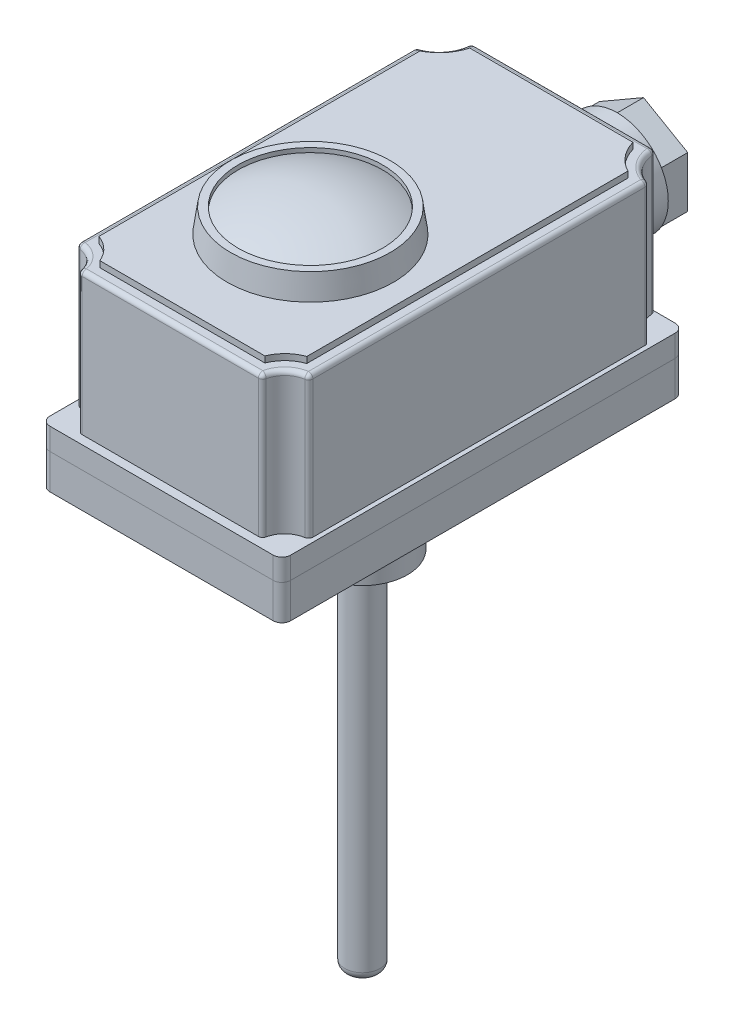
from build123d import *

# Parameters (mm, degrees)
SKICA1_W                 = 55
SKICA1_H                 = 91.8
P_IDAT_VYSUNUT_M1_DEPTH  = 8
SKICA2_W                 = 55
SKICA2_H                 = 91.8
P_IDAT_VYSUNUT_M2_DEPTH  = 5
P_IDAT_VYSUNUT_M3_DEPTH  = 32.3
P_IDAT_VYSUNUT_M4_DEPTH  = 1.4
ZAOBLIT1_R               = 1
ZAOBLIT1_2_R             = 2
ZAOBLIT2_R               = 2
SKICA5_R                 = 11.65
P_IDAT_VYSUNUT_M5_DEPTH  = 12.3
P_IDAT_VYSUNUT_M6_DEPTH  = 6
ODEBRAT_START            = 1
SKICA6_3_R               = 7.75
ODEBRAT_VYSUNUT_M1_DEPTH = 5
SKICA9_R                 = 19
P_IDAT_VYSUNUT_M8_DEPTH  = 5.5
P_IDAT_VYSUNUT_M8_TAPER  = 8
SKICA10_R                = 16.5
ODEBRAT_VYSUNUT_M2_DEPTH = 1
KOPULE1_FACE_RADIUS      = 16.5
KOPULE1_HEIGHT           = 4
SKICA11_R                = 16.5
SKICA11_R_2              = 13.25
P_IDAT_VYSUNUT_M9_DEPTH  = 10
P_IDAT_VYSUNUT_M10_DEPTH = 11
SKICA13_R                = 10.25
P_IDAT_VYSUNUT_M11_DEPTH = 10.5
SKICA14_R                = 4
P_IDAT_VYSUNUT_M12_DEPTH = 83
ZAOBLIT3_R               = 2


with BuildPart() as part:
    # Skica1 → P_idat vysunut_m1 (new body)
    with BuildSketch(Plane(origin=(0, 0, 0), x_dir=(1, 0, 0), z_dir=(0, 1, 0))):
        Rectangle(SKICA1_W, SKICA1_H)
    extrude(amount=P_IDAT_VYSUNUT_M1_DEPTH)

    # Zaoblit2
    zaoblit2_edges = [part.edges().sort_by_distance(p)[0] for p in [
        (27.5, 4, 45.9),
        (-27.5, 4, 45.9),
        (-27.5, 4, -45.9),
        (27.5, 4, -45.9),
    ]]
    fillet(zaoblit2_edges, radius=ZAOBLIT2_R)

    # Skica11 → P_idat vysunut_m9 (add)
    with BuildSketch(Plane.XZ):
        with Locations(Location((0, 0, 0), (0, 0, 270))):  # turned: the seam where the file's is
            Circle(SKICA11_R)
        with Locations(Location((0, 0, 0), (0, 0, 270))):  # turned: the seam where the file's is
            Circle(SKICA11_R_2, mode=Mode.SUBTRACT)
    extrude(amount=P_IDAT_VYSUNUT_M9_DEPTH)


with BuildPart() as body_2:
    # Skica2 → P_idat vysunut_m2 (new body)
    with BuildSketch(Plane(origin=(0, 8, 0), x_dir=(1, 0, 0), z_dir=(0, 1, 0))):
        Rectangle(SKICA2_W, SKICA2_H)
    extrude(amount=P_IDAT_VYSUNUT_M2_DEPTH)

    # Skica3 → P_idat vysunut_m3 (add)
    with BuildSketch(Plane(origin=(0, 13, 0), x_dir=(1, 0, 0), z_dir=(0, 1, 0))):
        with BuildLine():
            Line((21, 45.9), (-21, 45.9))
            ThreePointArc((-21, 45.9), (-22.534064041, 41.389664647), (-26.5, 38.75))
            Line((-26.5, 38.75), (-26.5, -38.75))
            ThreePointArc((-26.5, -38.75), (-22.732623592, -40.238481506), (-21, -43.9))
            Line((-21, -43.9), (21, -43.9))
            ThreePointArc((21, -43.9), (22.732623592, -40.238481506), (26.5, -38.75))
            Line((26.5, -38.75), (26.5, 38.75))
            ThreePointArc((26.5, 38.75), (22.534064041, 41.389664647), (21, 45.9))
        make_face()
    extrude(amount=P_IDAT_VYSUNUT_M3_DEPTH)

    # Skica4 → P_idat vysunut_m4 (add)
    with BuildSketch(Plane(origin=(0, 45.3, 0), x_dir=(1, 0, 0), z_dir=(0, 1, 0))):
        with BuildLine():
            Line((-23.75, 36.879329293), (-23.75, -36.471105098))
            ThreePointArc((-23.75, -36.471105098), (-20.796417226, -38.284600936), (-18.846569397, -41.15))
            Line((-18.846569397, -41.15), (18.846569397, -41.15))
            ThreePointArc((18.846569397, -41.15), (20.796417226, -38.284600936), (23.75, -36.471105098))
            Line((23.75, -36.471105098), (23.75, 36.879329293))
            ThreePointArc((23.75, 36.879329293), (20.537455307, 39.481943154), (18.629733815, 43.15))
            Line((18.629733815, 43.15), (-18.629733815, 43.15))
            ThreePointArc((-18.629733815, 43.15), (-20.537455307, 39.481943154), (-23.75, 36.879329293))
        make_face()
    extrude(amount=P_IDAT_VYSUNUT_M4_DEPTH)

    # Zaoblit1
    zaoblit1_edges = [body_2.edges().sort_by_distance(p)[0] for p in [
        (-21, 29.15, -45.9),
        (21, 29.15, -45.9),
        (22.534064041, 45.3, -41.389664647),
        (0, 45.3, -45.9),
        (26.5, 29.15, -38.75),
        (26.5, 45.3, 0),
        (-22.534064041, 45.3, -41.389664647),
        (-26.5, 29.15, -38.75),
        (-26.5, 45.3, 0),
        (-26.5, 29.15, 38.75),
        (-22.732623592, 45.3, 40.238481506),
        (-21, 29.15, 43.9),
        (0, 45.3, 43.9),
        (22.732623592, 45.3, 40.238481506),
        (21, 29.15, 43.9),
        (26.5, 29.15, 38.75),
    ]]
    fillet(zaoblit1_edges, radius=ZAOBLIT1_R)

    # Zaoblit1 2
    zaoblit1_2_edges = [body_2.edges().sort_by_distance(p)[0] for p in [
        (-27.5, 10.5, 45.9),
        (27.5, 10.5, 45.9),
        (-27.5, 10.5, -45.9),
        (27.5, 10.5, -45.9),
    ]]
    fillet(zaoblit1_2_edges, radius=ZAOBLIT1_2_R)

    # Skica5 → P_idat vysunut_m5 (add)
    with BuildSketch(Plane(origin=(0, 0, -45.9), x_dir=(-1, 0, 0), z_dir=(0, 0, -1))):
        with Locations(Location((0, 24.046001382, 0), (0, 0, 180))):  # turned: the seam where the file's is
            Circle(SKICA5_R)
    extrude(amount=P_IDAT_VYSUNUT_M5_DEPTH)

    # Skica9 → P_idat vysunut_m8 (add)
    with BuildSketch(Plane(origin=(0, 46.7, 0), x_dir=(1, 0, 0), z_dir=(0, 1, 0))):
        with Locations((0, -11.9)):
            Circle(SKICA9_R)
    extrude(amount=P_IDAT_VYSUNUT_M8_DEPTH, taper=P_IDAT_VYSUNUT_M8_TAPER)

    # Skica10 → Odebrat vysunut_m2 (cut)
    with BuildSketch(Plane(origin=(0, 52.2, 0), x_dir=(1, 0, 0), z_dir=(0, 1, 0))):
        with Locations(Location((0, -11.9, 0), (0, 0, 270))):  # turned: the seam where the file's is
            Circle(SKICA10_R)
    extrude(amount=-ODEBRAT_VYSUNUT_M2_DEPTH, mode=Mode.SUBTRACT)

    # Kopule1: a dome of height H over a round flat face of radius A is a cap of a sphere of radius (A * A + H * H) / (2 * H)
    kopule1_r = (KOPULE1_FACE_RADIUS * KOPULE1_FACE_RADIUS + KOPULE1_HEIGHT * KOPULE1_HEIGHT) / (2 * KOPULE1_HEIGHT)
    kopule1_base = Plane((0, 51.2, 11.9), z_dir=(0, 1, 0))
    with Locations(kopule1_base.offset(KOPULE1_HEIGHT - kopule1_r)):
        kopule1_ball = Sphere(kopule1_r, mode=Mode.PRIVATE)
    add(split(kopule1_ball, bisect_by=kopule1_base, keep=Keep.TOP, mode=Mode.PRIVATE))


with BuildPart() as body_3:
    # Skica6 → P_idat vysunut_m6 (new body)
    with BuildSketch(Plane(origin=(0, 0, -58.2), x_dir=(-1, 0, 0), z_dir=(0, 0, -1))):
        Polygon((0, 35.696001382), (-10.089195954, 29.871001382), (-10.089195954, 18.221001382), (0, 12.396001382), (10.089195954, 18.221001382), (10.089195954, 29.871001382), align=None)
    extrude(amount=P_IDAT_VYSUNUT_M6_DEPTH)

    # Skica6_3 → Odebrat vysunut_m1 (cut)
    with BuildSketch(Plane(origin=(0, 0, -58.2), x_dir=(-1, 0, 0), z_dir=(0, 0, -1)).offset(ODEBRAT_START)):
        with Locations((0, 24.046001382)):
            Circle(SKICA6_3_R)
    extrude(amount=ODEBRAT_VYSUNUT_M1_DEPTH, mode=Mode.SUBTRACT)


with BuildPart() as body_4:
    # Skica12 → P_idat vysunut_m10 (new body)
    with BuildSketch(Plane.XZ):
        Polygon((11.4748366, 6.625), (0, 13.25), (-11.4748366, 6.625), (-11.4748366, -6.625), (0, -13.25), (11.4748366, -6.625), align=None)
    extrude(amount=P_IDAT_VYSUNUT_M10_DEPTH)

    # Skica13 → P_idat vysunut_m11 (add)
    with BuildSketch(Plane.XZ.offset(11)):
        with Locations(Location((0, 0, 0), (0, 0, 270))):  # turned: the seam where the file's is
            Circle(SKICA13_R)
    extrude(amount=P_IDAT_VYSUNUT_M11_DEPTH)

    # Skica14 → P_idat vysunut_m12 (add)
    with BuildSketch(Plane.XZ.offset(21.5)):
        with Locations(Location((0, 0, 0), (0, 0, 270))):  # turned: the seam where the file's is
            Circle(SKICA14_R)
    extrude(amount=P_IDAT_VYSUNUT_M12_DEPTH)

    # Zaoblit3
    zaoblit3_edges = [body_4.edges().sort_by_distance(p)[0] for p in [
        (0, -21.5, 4),
        (0, -104.5, 4),
    ]]
    fillet(zaoblit3_edges, radius=ZAOBLIT3_R)


solid = Compound([part.part, body_2.part, body_3.part, body_4.part])
